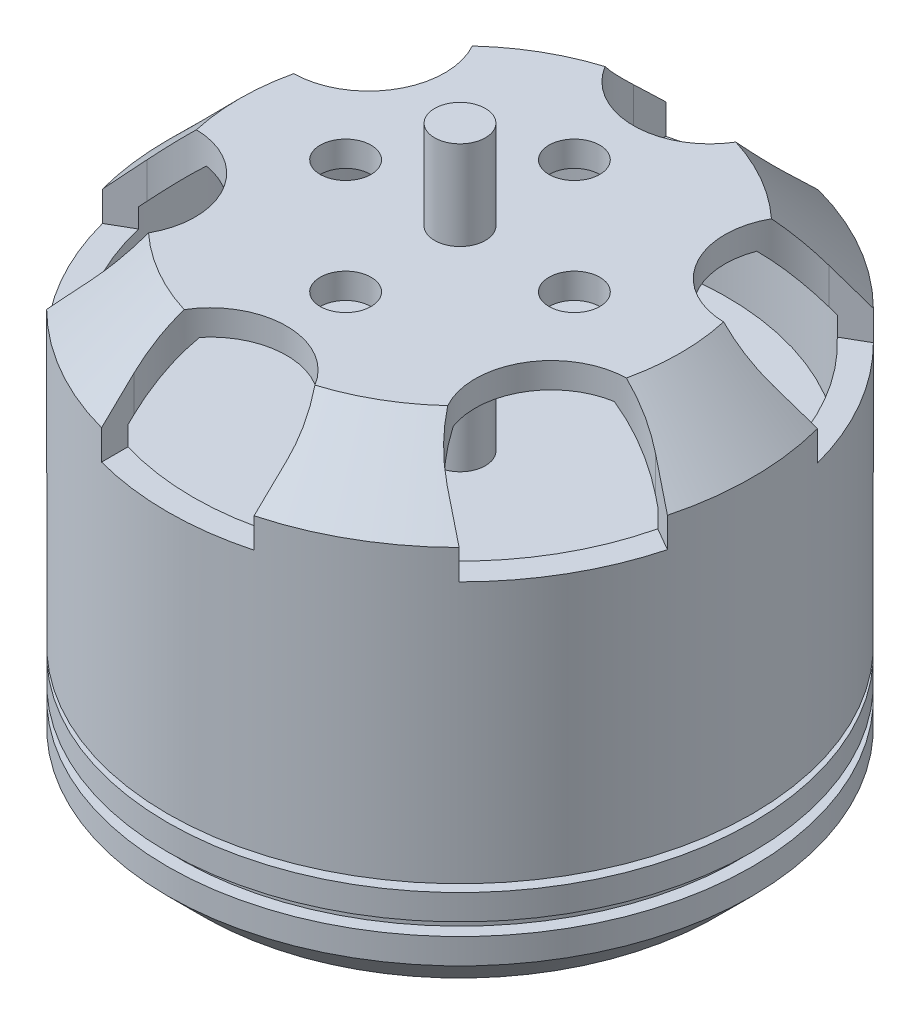
from build123d import *

# Parameters (mm, degrees)
SKETCH2_R          = 1
CUT_EXTRUDE1_DEPTH = 4
SKETCH3_R          = 1
CUT_EXTRUDE2_DEPTH = 3


with BuildPart() as part:
    # Sketch1 → Revolve1 (revolve)
    with BuildSketch(Plane.XY):
        Polygon((0, 21.642718579), (0, 0), (0, -2.157281421), (1, -2.157281421), (1, -0.357281421), (10.085786438, -0.357281421), (11.5, 1.056932142), (11.5, 2.056932142), (11, 2.056932142), (11, 2.556932142), (11.5, 2.556932142), (11.5, 3.556932142), (9.5, 3.556932142), (9.5, 3.856932142), (11.5, 3.856932142), (11.5, 15.314291455), (8.671572875, 18.142718579), (1, 18.142718579), (1, 21.642718579), align=None)
        Polygon((2, 17.142718579), (8.257359313, 17.142718579), (10.5, 14.900077892), (10.5, 10.467720713), (1, 10.467720713), (1, 16.142718579), (2, 16.142718579), align=None, mode=Mode.SUBTRACT)
    revolve(axis=Axis((0, 21.642718579, 0), (0, -1, 0)))

    # Sketch2 → Cut-Extrude1 (cut)
    with BuildSketch(Plane(origin=(0, 18.142718579, 0), x_dir=(1, 0, 0), z_dir=(0, 1, 0))):
        with Locations((0, -4.5)):
            Circle(SKETCH2_R)
        with Locations((-4.5, 0)):
            Circle(SKETCH2_R)
        with Locations((0, 4.5)):
            Circle(SKETCH2_R)
        with Locations((4.5, 0)):
            Circle(SKETCH2_R)
        with BuildLine():
            Line((-3, 9.824499933), (-3, 15.547294435))
            Line((-3, 15.547294435), (3, 15.547294435))
            Line((3, 15.547294435), (3, 9.824499933))
            ThreePointArc((3, 9.824499933), (0, 6.824499933), (-3, 9.824499933))
        make_face()
        with BuildLine():
            Line((11.964351941, 10.371723429), (14.964351941, 5.175571006))
            Line((14.964351941, 5.175571006), (10.008266522, 2.314173755))
            ThreePointArc((10.008266522, 2.314173755), (5.91019031, 3.412249967), (7.008266522, 7.510326178))
            Line((7.008266522, 7.510326178), (11.964351941, 10.371723429))
        make_face()
        with BuildLine():
            Line((14.964351941, -5.175571006), (11.964351941, -10.371723429))
            Line((11.964351941, -10.371723429), (7.008266522, -7.510326178))
            ThreePointArc((7.008266522, -7.510326178), (5.91019031, -3.412249967), (10.008266522, -2.314173755))
            Line((10.008266522, -2.314173755), (14.964351941, -5.175571006))
        make_face()
        with BuildLine():
            Line((3, -15.547294435), (-3, -15.547294435))
            Line((-3, -15.547294435), (-3, -9.824499933))
            ThreePointArc((-3, -9.824499933), (0, -6.824499933), (3, -9.824499933))
            Line((3, -9.824499933), (3, -15.547294435))
        make_face()
        with BuildLine():
            Line((-11.964351941, -10.371723429), (-14.964351941, -5.175571006))
            Line((-14.964351941, -5.175571006), (-10.008266522, -2.314173755))
            ThreePointArc((-10.008266522, -2.314173755), (-5.91019031, -3.412249967), (-7.008266522, -7.510326178))
            Line((-7.008266522, -7.510326178), (-11.964351941, -10.371723429))
        make_face()
        with BuildLine():
            Line((-14.964351941, 5.175571006), (-11.964351941, 10.371723429))
            Line((-11.964351941, 10.371723429), (-7.008266522, 7.510326178))
            ThreePointArc((-7.008266522, 7.510326178), (-5.91019031, 3.412249967), (-10.008266522, 2.314173755))
            Line((-10.008266522, 2.314173755), (-14.964351941, 5.175571006))
        make_face()
    extrude(amount=-CUT_EXTRUDE1_DEPTH, mode=Mode.SUBTRACT)

    # Sketch3 → Cut-Extrude2 (cut)
    with BuildSketch(Plane.XZ.offset(0.357281421)):
        with Locations((0, -6)):
            Circle(SKETCH3_R)
        with Locations((0, 6)):
            Circle(SKETCH3_R)
        with Locations((-8, 0)):
            Circle(SKETCH3_R)
        with Locations((8, 0)):
            Circle(SKETCH3_R)
    extrude(amount=-CUT_EXTRUDE2_DEPTH, mode=Mode.SUBTRACT)


solid = part.part
